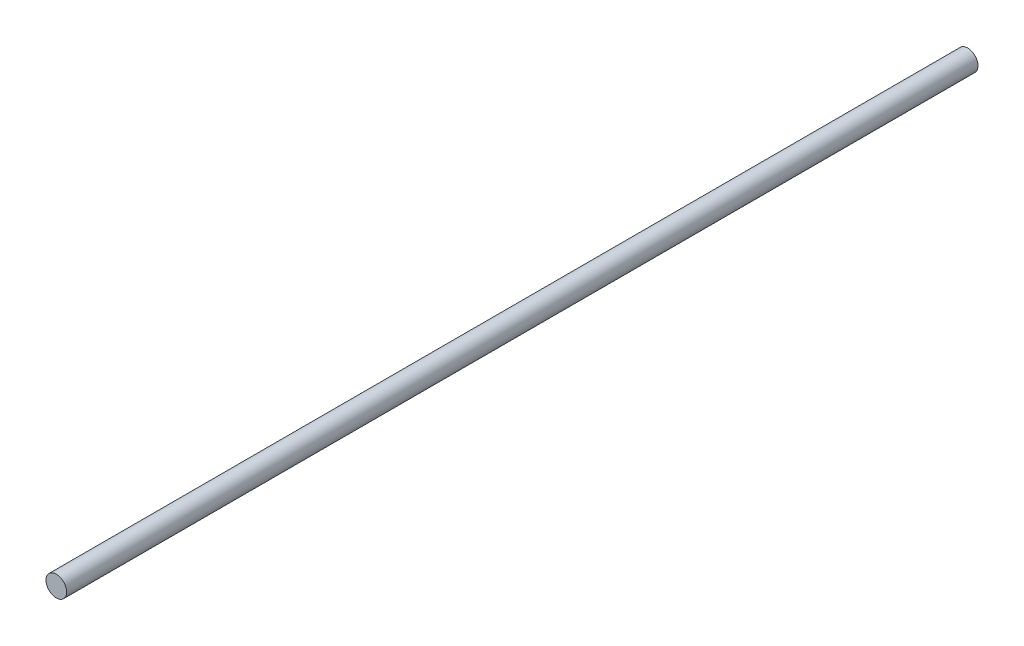
from build123d import *

# Parameters (mm, degrees)
SKETCH1_R           = 3
BOSS_EXTRUDE1_DEPTH = 265


with BuildPart() as part:
    # Sketch1 → Boss-Extrude1 (new body)
    with BuildSketch(Plane.XY):
        Circle(SKETCH1_R)
    extrude(amount=BOSS_EXTRUDE1_DEPTH)


solid = part.part
